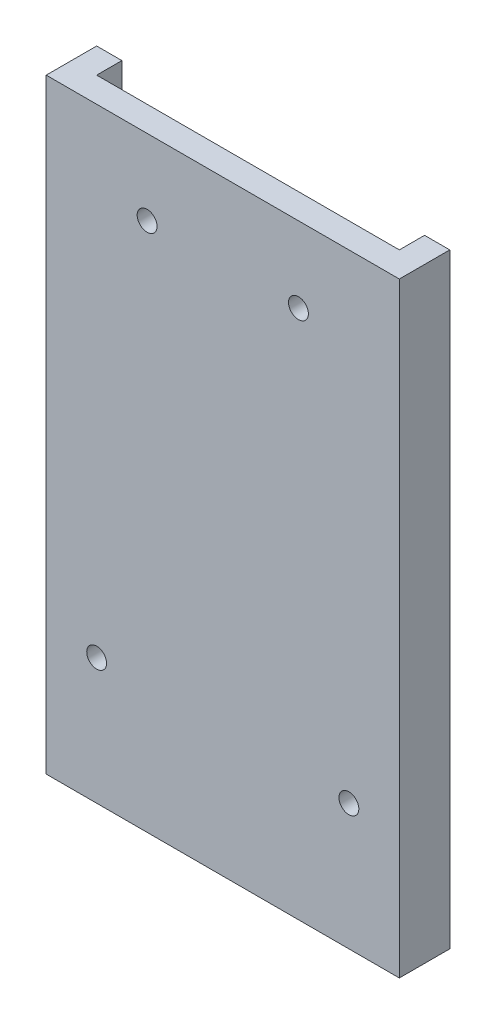
from build123d import *

# Parameters (mm, degrees)
SKETCH1_W           = 44.45
SKETCH1_H           = 6.35
BOSS_EXTRUDE1_DEPTH = 76.2
SKETCH2_W           = 38.1
SKETCH2_H           = 3.175
CUT_EXTRUDE1_DEPTH  = 73.025
SKETCH4_R           = 1.25
CUT_EXTRUDE2_DEPTH  = 4.175


with BuildPart() as part:
    # Sketch1 → Boss-Extrude1 (new body)
    with BuildSketch(Plane(origin=(0, 0, 0), x_dir=(1, 0, 0), z_dir=(0, 1, 0))):
        Rectangle(SKETCH1_W, SKETCH1_H)
    extrude(amount=BOSS_EXTRUDE1_DEPTH)

    # Sketch2 → Cut-Extrude1 (cut)
    with BuildSketch(Plane(origin=(0, 76.2, 0), x_dir=(1, 0, 0), z_dir=(0, 1, 0))):
        with Locations((0, 1.5875)):
            Rectangle(SKETCH2_W, SKETCH2_H)
    extrude(amount=-CUT_EXTRUDE1_DEPTH, mode=Mode.SUBTRACT)

    # Sketch4 → Cut-Extrude2 (cut, through all)
    with BuildSketch(Plane(origin=(0, 0, 0), x_dir=(-1, 0, 0), z_dir=(0, 0, -1))):
        with Locations((-9.525, 66.675)):
            Circle(SKETCH4_R)
        with Locations((9.525, 66.675)):
            Circle(SKETCH4_R)
        with Locations((-15.875, 15.875)):
            Circle(SKETCH4_R)
        with Locations((15.875, 15.875)):
            Circle(SKETCH4_R)
    extrude(amount=-CUT_EXTRUDE2_DEPTH, mode=Mode.SUBTRACT)


solid = part.part
